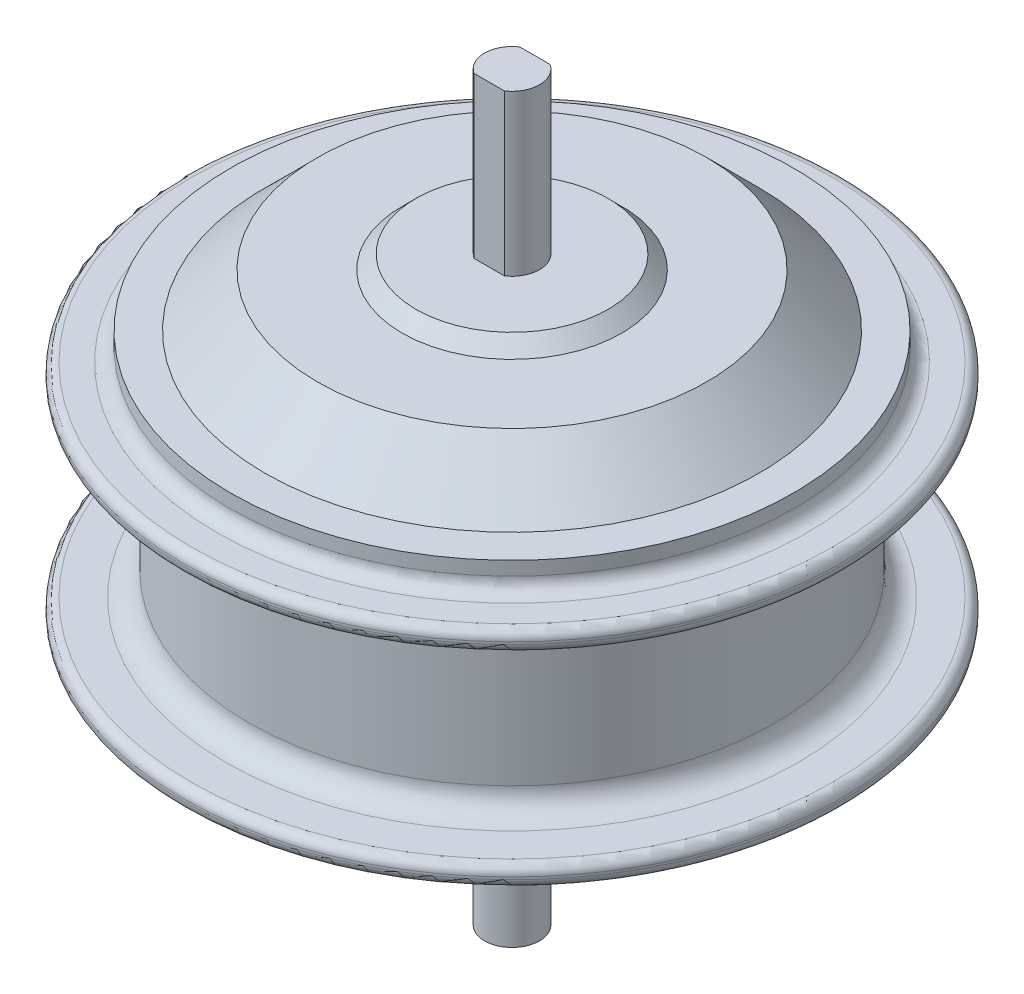
from build123d import *

# Parameters (mm, degrees)
FILLET_1_R          = 2
FILLET_2_R          = 5
FILLET_3_R          = 3
CUT_EXTRUDE_1_DEPTH = 35


with BuildPart() as part:
    # Эскиз1 → Повернуть1 (revolve)
    with BuildSketch(Plane(origin=(0, 0, 0), x_dir=(0, 0, -1), z_dir=(1, 0, 0))):
        Polygon((0, 80), (-6, 80), (-6, 45), (-21, 45), (-24, 42), (-42.5, 42), (-54, 30.5), (-61.5, 30.5), (-61.5, 24.5), (-72, 24.5), (-72, 20), (-57.5, 20), (-57.5, -20), (-72, -20), (-72, -24.5), (-61.5, -24.5), (-61.5, -30.5), (-54, -30.5), (-42.5, -42), (-26.65, -42), (-26.65, -51), (-6, -51), (-6, -82), (0, -82), align=None)
    revolve(axis=Axis((0, 80, 0), (0, -1, 0)))

    # Скругление1
    fillet_1_edges = [part.edges().sort_by_distance(p)[0] for p in [
        (0, -24.5, -72),
        (0, -20, -72),
        (0, 20, -72),
        (0, 24.5, -72),
    ]]
    fillet(fillet_1_edges, radius=FILLET_1_R)

    # Скругление2
    fillet_2_edges = [part.edges().sort_by_distance(p)[0] for p in [
        (0, -20, -57.5),
        (0, 20, -57.5),
    ]]
    fillet(fillet_2_edges, radius=FILLET_2_R)

    # Скругление3
    fillet_3_edges = [part.edges().sort_by_distance(p)[0] for p in [
        (0, -24.5, -61.5),
        (0, 24.5, -61.5),
    ]]
    fillet(fillet_3_edges, radius=FILLET_3_R)

    # Эскиз2 → Вырез-Вытянуть1 (cut)
    with BuildSketch(Plane(origin=(0, 80, 0), x_dir=(1, 0, 0), z_dir=(0, 1, 0))):
        with BuildLine():
            Line((-3.31662479, 5), (3.31662479, 5))
            ThreePointArc((3.31662479, 5), (0, 6), (-3.31662479, 5))
        make_face()
        with BuildLine():
            Line((-3.31662479, -5), (3.31662479, -5))
            ThreePointArc((3.31662479, -5), (0, -6), (-3.31662479, -5))
        make_face()
    extrude(amount=-CUT_EXTRUDE_1_DEPTH, mode=Mode.SUBTRACT)


solid = part.part
